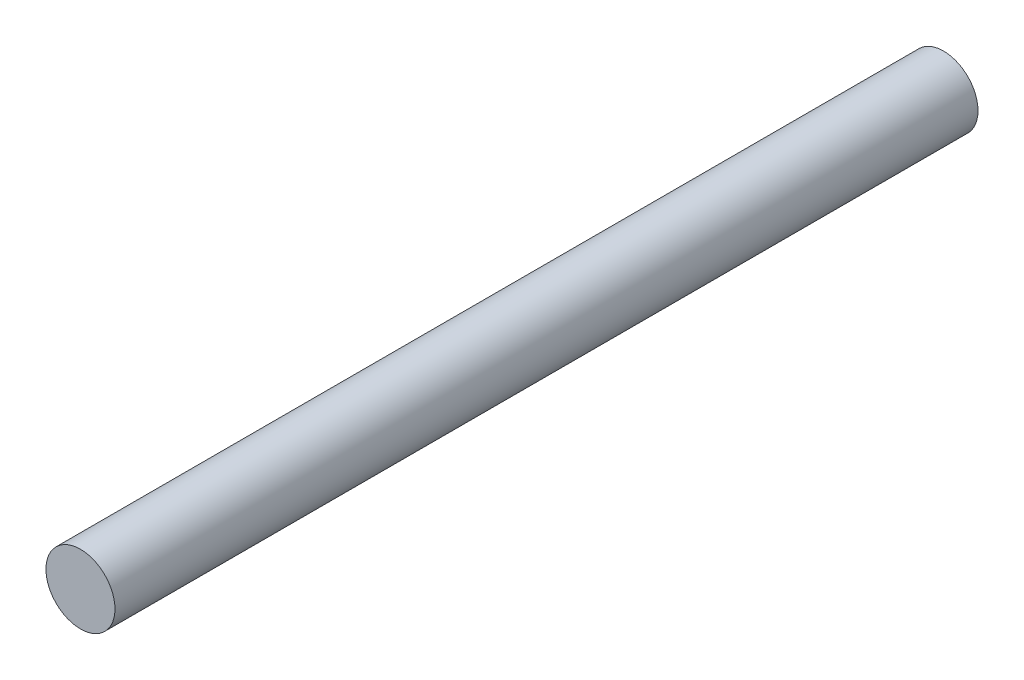
from build123d import *

# Parameters (mm, degrees)
SKETCH1_R           = 1.27
BOSS_EXTRUDE1_DEPTH = 15.875


with BuildPart() as part:
    # Sketch1 → Boss-Extrude1 (new body, symmetric)
    with BuildSketch(Plane.XY):
        Circle(SKETCH1_R)
    extrude(amount=BOSS_EXTRUDE1_DEPTH, both=True)


solid = part.part
